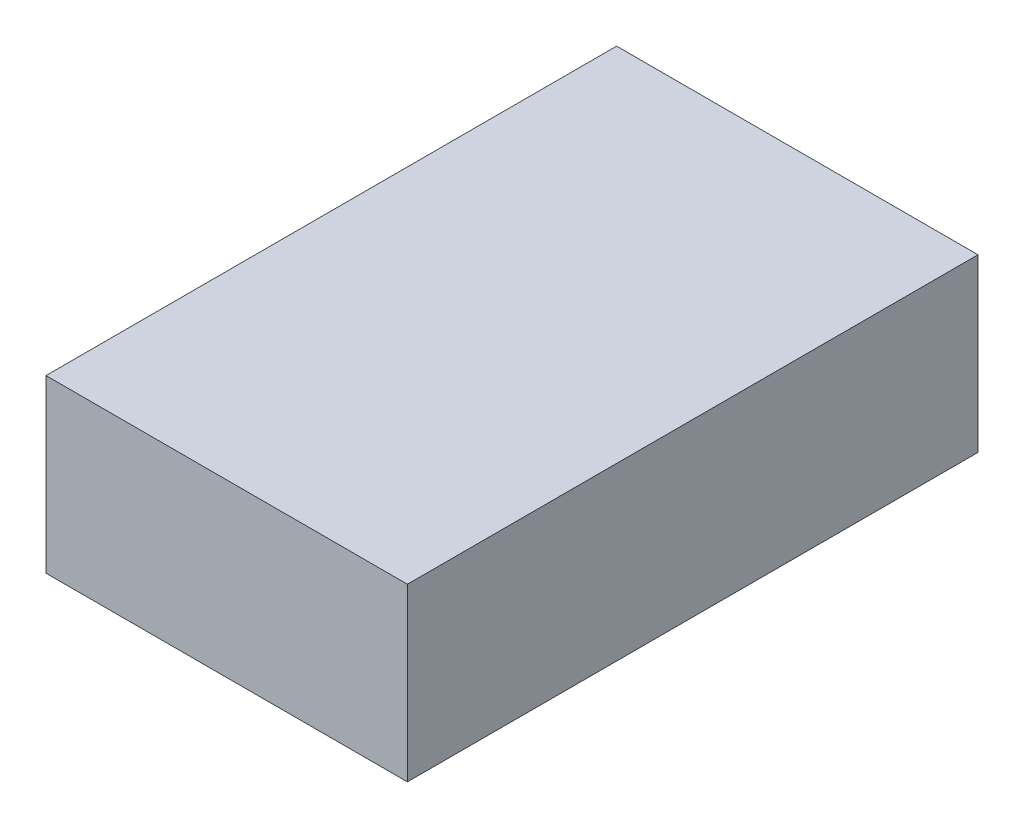
from build123d import *

# Parameters (mm, degrees)
SKETCH1_W           = 19
SKETCH1_H           = 30
BOSS_EXTRUDE1_DEPTH = 9


with BuildPart() as part:
    # Sketch1 → Boss-Extrude1 (new body)
    with BuildSketch(Plane(origin=(0, 0, 0), x_dir=(1, 0, 0), z_dir=(0, 1, 0))):
        with Locations((9.5, 15)):
            Rectangle(SKETCH1_W, SKETCH1_H)
    extrude(amount=BOSS_EXTRUDE1_DEPTH)


solid = part.part
